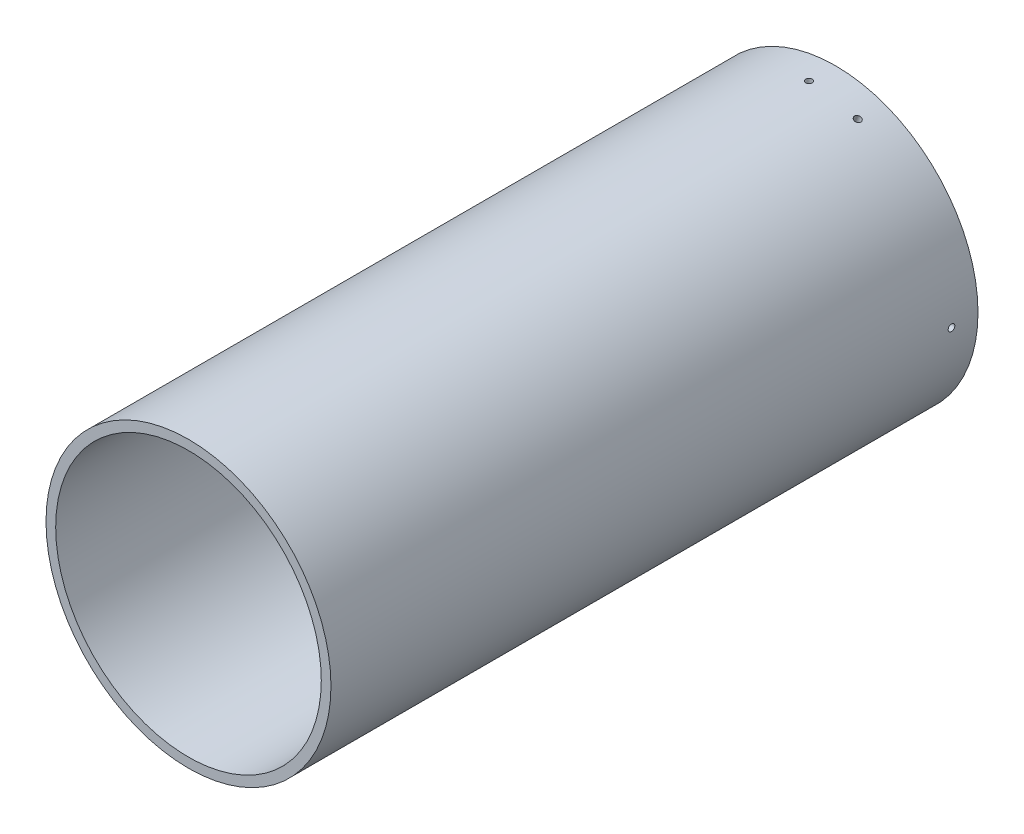
from build123d import *

# Parameters (mm, degrees)
SKETCH11_R                    = 136.525
SKETCH11_R_2                  = 127.254
PIPE_STANDARD_S40_P10_1_DEPTH = 620
SKETCH12_R                    = 3.175
CUT_EXTRUDE1_DEPTH            = 650.367500919
SKETCH14_R                    = 3.175
CUT_EXTRUDE2_DEPTH            = 650.367501057
SKETCH15_R                    = 3.175
CUT_EXTRUDE3_DEPTH            = 650.367501057


with BuildPart() as part:
    # Sketch11 → Pipe (standard, s40) P10(1) (new body)
    with BuildSketch(Plane(origin=(0, 0, 0), x_dir=(-1, 0, 0), z_dir=(0, 0, -1))):
        Circle(SKETCH11_R)
        Circle(SKETCH11_R_2, mode=Mode.SUBTRACT)
    extrude(amount=PIPE_STANDARD_S40_P10_1_DEPTH)

    # Sketch12 → Cut-Extrude1 (cut, through all)
    with BuildSketch(Plane(origin=(0, 0, 0), x_dir=(1, 0, 0), z_dir=(0, 1, 0))):
        with Locations(Location((0, 594.6, 0), (0, 0, 90))):
            Circle(SKETCH12_R)
    extrude(amount=CUT_EXTRUDE1_DEPTH, mode=Mode.SUBTRACT)

    # Sketch14 → Cut-Extrude2 (cut, through all)
    with BuildSketch(Plane(origin=(0, 0, 0), x_dir=(0, 0, 1), z_dir=(-0.3420201433256631, -0.9396926207859105, 0))):
        with Locations(Location((-594.6, 0, 0), (0, 0, 270))):
            Circle(SKETCH14_R)
    extrude(amount=-CUT_EXTRUDE2_DEPTH, mode=Mode.SUBTRACT)

    # Sketch15 → Cut-Extrude3 (cut, through all)
    with BuildSketch(Plane(origin=(0, 0, 0), x_dir=(0, 0, -1), z_dir=(1, 0, 0))):
        with Locations(Location((594.6, 0, 0), (0, 0, 180))):
            Circle(SKETCH15_R)
    extrude(amount=CUT_EXTRUDE3_DEPTH, mode=Mode.SUBTRACT)


solid = part.part
